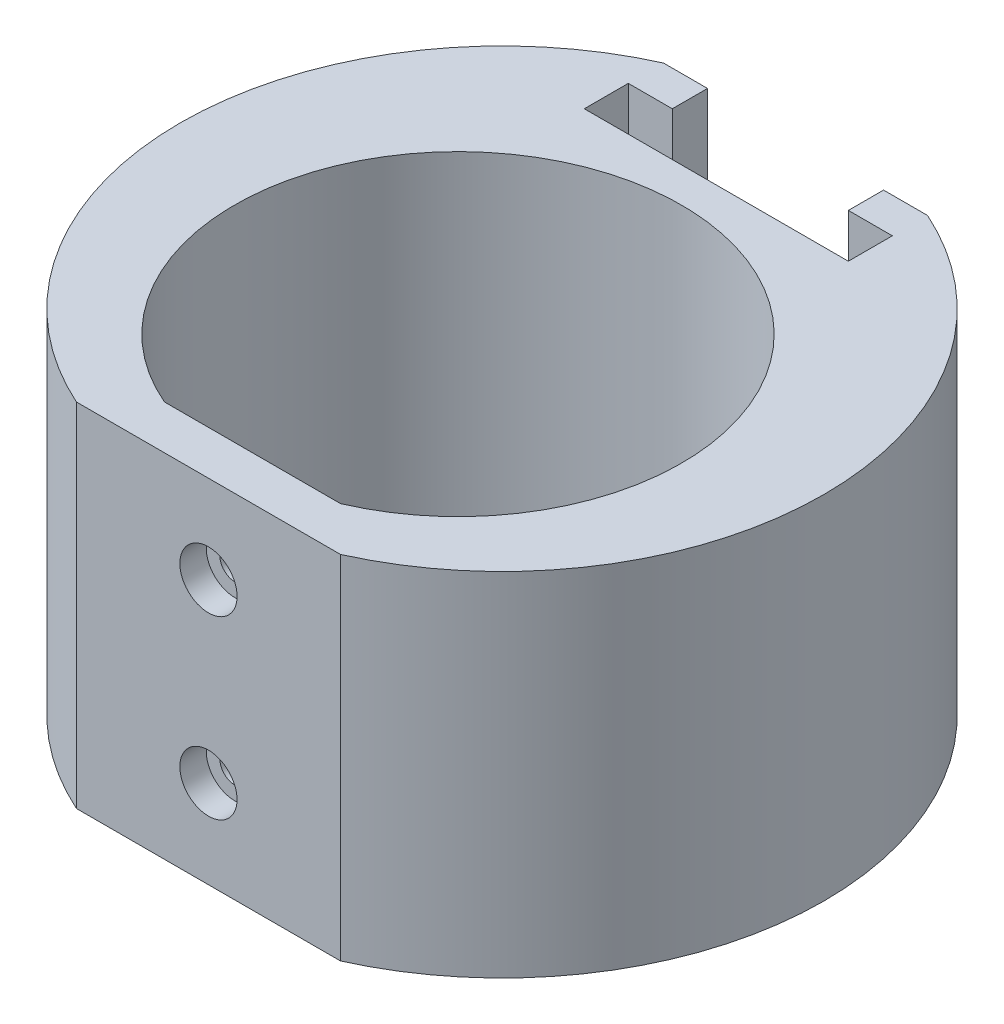
from build123d import *

# Parameters (mm, degrees)
BOSS_EXTRUDE1_DEPTH            = 20
CUT_EXTRUDE1_DEPTH             = 27.5
FILLET1_R                      = 4
CBORE_FOR_M3_SHCS1_D           = 3.4
CBORE_FOR_M3_SHCS1_DEPTH       = 5
CBORE_FOR_M3_SHCS1_CBORE_D     = 6.5
CBORE_FOR_M3_SHCS1_CBORE_DEPTH = 3
M3X0_5_TAPPED_HOLE1_D          = 2.5
M3X0_5_TAPPED_HOLE1_DEPTH      = 11
M3X0_5_TAPPED_HOLE1_TIP        = 0.751075774


with BuildPart() as part:
    # Sketch1 → Boss-Extrude1 (new body, symmetric)
    with BuildSketch(Plane(origin=(0, 0, 0), x_dir=(1, 0, 0), z_dir=(0, 1, 0))):
        with BuildLine():
            Line((-15, -28.348661632), (15, -28.348661632))
            ThreePointArc((15, -28.348661632), (36.566832412, 5), (15, 38.348661632))
            Line((15, 38.348661632), (-15, 38.348661632))
            ThreePointArc((-15, 38.348661632), (-36.566832412, 5), (-15, -28.348661632))
        make_face()
        with BuildLine():
            Line((-10, -23.348661632), (10, -23.348661632))
            ThreePointArc((10, -23.348661632), (0, 25.4), (-10, -23.348661632))
        make_face(mode=Mode.SUBTRACT)
    extrude(amount=BOSS_EXTRUDE1_DEPTH, both=True)

    # Sketch3 → Cut-Extrude1 (cut)
    with BuildSketch(Plane(origin=(0, 20, 0), x_dir=(1, 0, 0), z_dir=(0, 1, 0))):
        Polygon((-10, 38.348661632), (-10, 34.348661632), (-15, 34.348661632), (-15, 29.348661632), (15, 29.348661632), (15, 34.348661632), (10, 34.348661632), (10, 38.348661632), align=None)
    extrude(amount=-CUT_EXTRUDE1_DEPTH, mode=Mode.SUBTRACT)

    # Fillet1
    fillet1_edges = [part.edges().sort_by_distance(p)[0] for p in [
        (10, -7.5, -36.348661632),
        (15, -7.5, -31.848661632),
        (-15, -7.5, -31.848661632),
        (-10, -7.5, -36.348661632),
    ]]
    fillet(fillet1_edges, radius=FILLET1_R)

    # CBORE for M3 SHCS1
    with Locations(Plane.XY.offset(28.348661632)):
        with Locations((0, 10), (0, -10)):
            CounterBoreHole(CBORE_FOR_M3_SHCS1_D / 2, CBORE_FOR_M3_SHCS1_CBORE_D / 2, CBORE_FOR_M3_SHCS1_CBORE_DEPTH, depth=CBORE_FOR_M3_SHCS1_DEPTH)

    # M3x0.5 Tapped Hole1
    with Locations(Plane(origin=(0, 0, -38.348661632), x_dir=(-1, 0, 0), z_dir=(0, 0, -1))):
        with Locations((0, 13.90875121)):
            Hole(M3X0_5_TAPPED_HOLE1_D / 2, depth=M3X0_5_TAPPED_HOLE1_DEPTH)
            with Locations((0, 0, -(M3X0_5_TAPPED_HOLE1_DEPTH + M3X0_5_TAPPED_HOLE1_TIP / 2))):  # 118° drill point
                Cone(0, M3X0_5_TAPPED_HOLE1_D / 2, M3X0_5_TAPPED_HOLE1_TIP, mode=Mode.SUBTRACT)


solid = part.part
